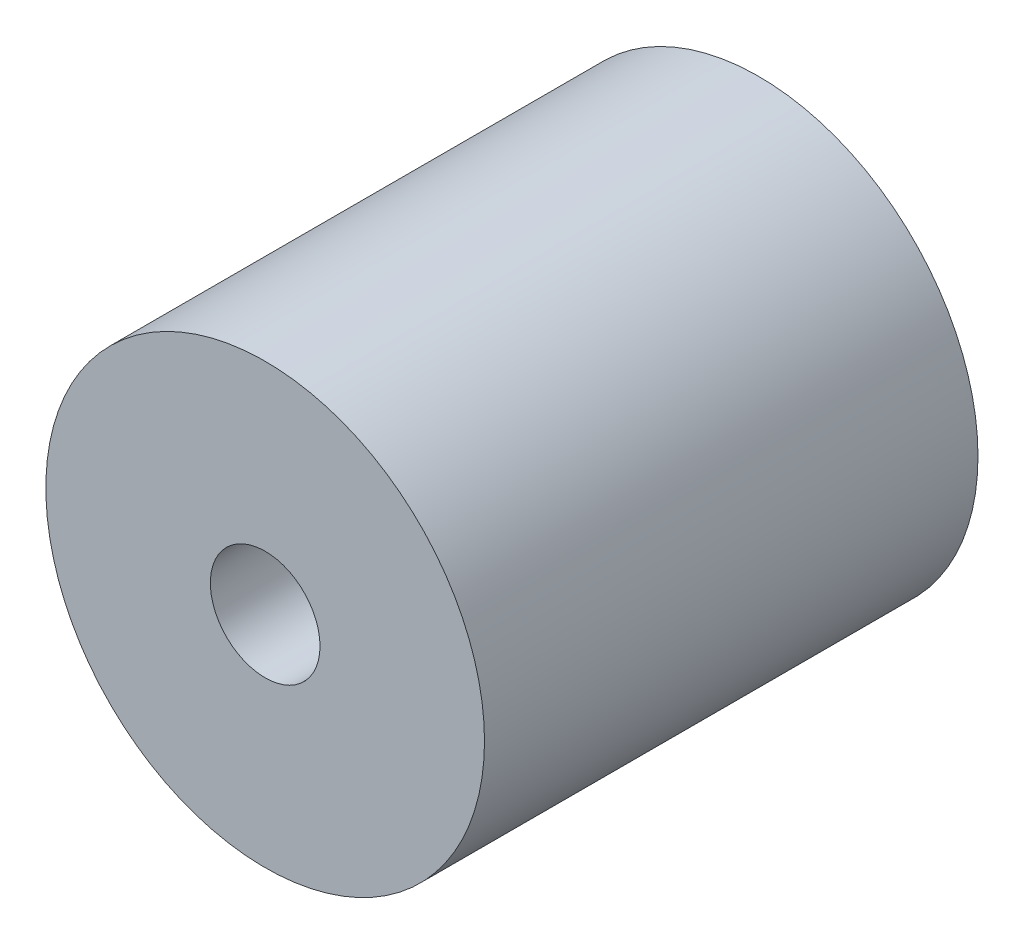
from build123d import *

# Parameters (mm, degrees)
SKETCH1_R           = 40
SKETCH1_R_2         = 10
BOSS_EXTRUDE1_DEPTH = 90


with BuildPart() as part:
    # Sketch1 → Boss-Extrude1 (new body)
    with BuildSketch(Plane.XY):
        Circle(SKETCH1_R)
        Circle(SKETCH1_R_2, mode=Mode.SUBTRACT)
    extrude(amount=BOSS_EXTRUDE1_DEPTH)


solid = part.part
